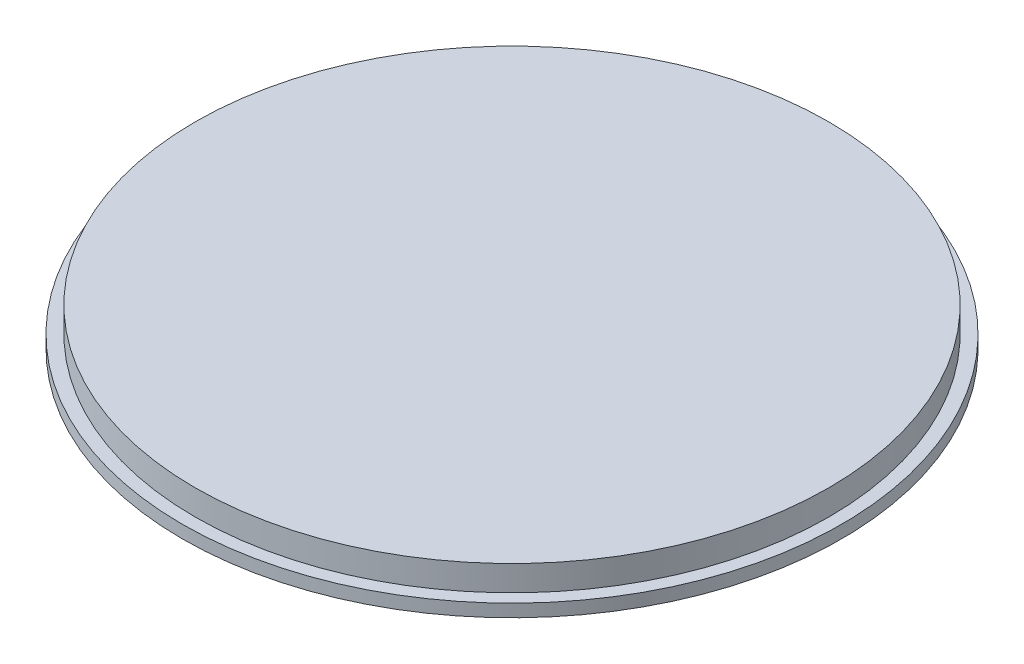
from build123d import *

# Parameters (mm, degrees)
SKETCH1_R           = 26
BOSS_EXTRUDE4_DEPTH = 1
SKETCH6_R           = 25
BOSS_EXTRUDE5_DEPTH = 2


with BuildPart() as part:
    # Sketch1 → Boss-Extrude4 (new body)
    with BuildSketch(Plane(origin=(0, 0, 0), x_dir=(1, 0, 0), z_dir=(0, 1, 0))):
        Circle(SKETCH1_R)
    extrude(amount=BOSS_EXTRUDE4_DEPTH)

    # Sketch6 → Boss-Extrude5 (add)
    with BuildSketch(Plane(origin=(0, 1, 0), x_dir=(1, 0, 0), z_dir=(0, 1, 0))):
        Circle(SKETCH6_R)
    extrude(amount=BOSS_EXTRUDE5_DEPTH)


solid = part.part
